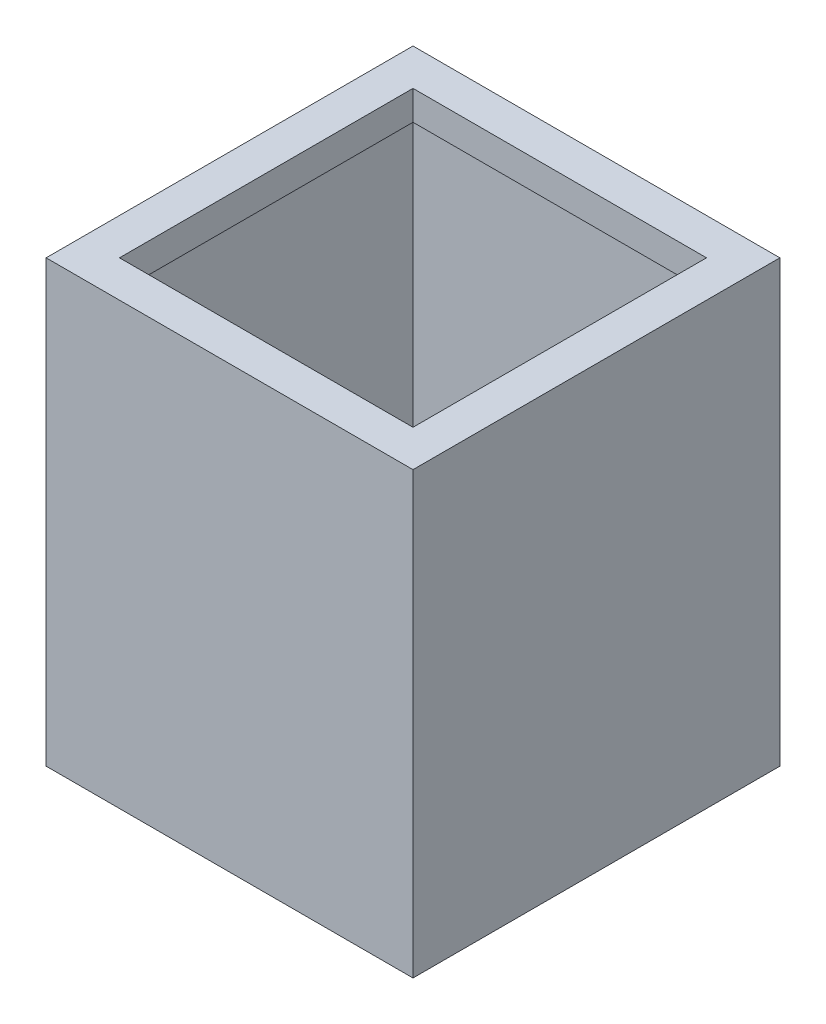
from build123d import *

# Parameters (mm, degrees)
SZKIC1_W                    = 250
SZKIC1_H                    = 250
DODANIE_WYCI_GNI_CIE1_DEPTH = 300
SZKIC2_W                    = 240
SZKIC2_H                    = 240
WYTNIJ_WYCI_GNI_CIE1_DEPTH  = 295
SZKIC3_W                    = 240
SZKIC3_H                    = 240
SZKIC3_W_2                  = 200
SZKIC3_H_2                  = 200
DODANIE_WYCI_GNI_CIE2_DEPTH = 20


with BuildPart() as part:
    # Szkic1 → Dodanie-wyciągnięcie1 (new body)
    with BuildSketch(Plane(origin=(0, 0, 0), x_dir=(1, 0, 0), z_dir=(0, 1, 0))):
        with Locations((-34.375, -85.9375)):
            Rectangle(SZKIC1_W, SZKIC1_H)
    extrude(amount=DODANIE_WYCI_GNI_CIE1_DEPTH)

    # Szkic2 → Wytnij-wyciągnięcie1 (cut)
    with BuildSketch(Plane(origin=(0, 300, 0), x_dir=(1, 0, 0), z_dir=(0, 1, 0))):
        with Locations((-34.375, -85.9375)):
            Rectangle(SZKIC2_W, SZKIC2_H)
    extrude(amount=-WYTNIJ_WYCI_GNI_CIE1_DEPTH, mode=Mode.SUBTRACT)

    # Szkic3 → Dodanie-wyciągnięcie2 (add)
    with BuildSketch(Plane(origin=(0, 300, 0), x_dir=(1, 0, 0), z_dir=(0, 1, 0))):
        with Locations((-34.375, -85.9375)):
            Rectangle(SZKIC3_W, SZKIC3_H)
        with Locations((-34.375, -85.9375)):
            Rectangle(SZKIC3_W_2, SZKIC3_H_2, mode=Mode.SUBTRACT)
    extrude(amount=-DODANIE_WYCI_GNI_CIE2_DEPTH)


solid = part.part
